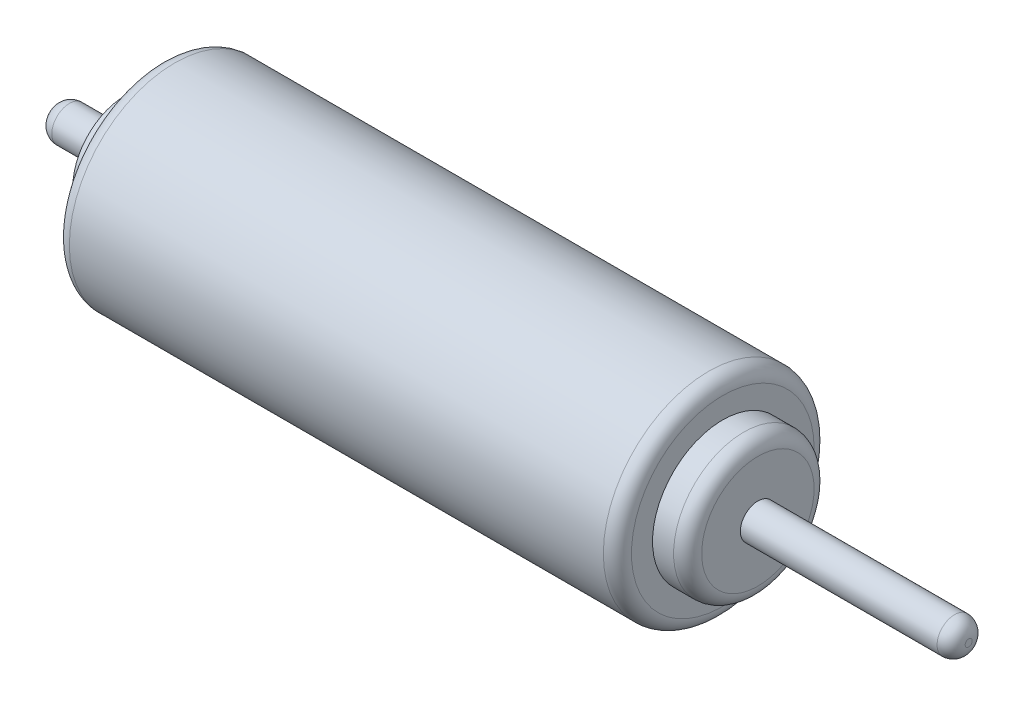
from build123d import *

# Parameters (mm, degrees)
SKETCH1_R           = 15
BOSS_EXTRUDE1_DEPTH = 80
SKETCH2_R           = 10
BOSS_EXTRUDE2_DEPTH = 5
SKETCH3_R           = 2.5
BOSS_EXTRUDE3_DEPTH = 30
FILLET1_R           = 2
FILLET2_R           = 2
FILLET3_R           = 2
SKETCH4_R           = 7.5
BOSS_EXTRUDE5_DEPTH = 5
SKETCH5_R           = 2.5
BOSS_EXTRUDE6_DEPTH = 10
FILLET4_R           = 2


with BuildPart() as part:
    # Sketch1 → Boss-Extrude1 (new body)
    with BuildSketch(Plane(origin=(0, 0, 0), x_dir=(0, 0, -1), z_dir=(1, 0, 0))):
        Circle(SKETCH1_R)
    extrude(amount=BOSS_EXTRUDE1_DEPTH)

    # Sketch2 → Boss-Extrude2 (add)
    with BuildSketch(Plane(origin=(80, 0, 0), x_dir=(0, 0, -1), z_dir=(1, 0, 0))):
        Circle(SKETCH2_R)
    extrude(amount=BOSS_EXTRUDE2_DEPTH)

    # Sketch3 → Boss-Extrude3 (add)
    with BuildSketch(Plane(origin=(85, 0, 0), x_dir=(0, 0, -1), z_dir=(1, 0, 0))):
        Circle(SKETCH3_R)
    extrude(amount=BOSS_EXTRUDE3_DEPTH)

    # Fillet1
    fillet1_edges = [part.edges().sort_by_distance(p)[0] for p in [
        (80, 0, 15),
    ]]
    fillet(fillet1_edges, radius=FILLET1_R)

    # Fillet2
    fillet2_edges = [part.edges().sort_by_distance(p)[0] for p in [
        (85, 0, 10),
    ]]
    fillet(fillet2_edges, radius=FILLET2_R)

    # Fillet3
    fillet3_edges = [part.edges().sort_by_distance(p)[0] for p in [
        (0, 0, 15),
    ]]
    fillet(fillet3_edges, radius=FILLET3_R)

    # Sketch4 → Boss-Extrude5 (add)
    with BuildSketch(Plane.ZY):
        Circle(SKETCH4_R)
    extrude(amount=BOSS_EXTRUDE5_DEPTH)

    # Sketch5 → Boss-Extrude6 (add)
    with BuildSketch(Plane.ZY.offset(5)):
        Circle(SKETCH5_R)
    extrude(amount=BOSS_EXTRUDE6_DEPTH)

    # Fillet4
    fillet4_edges = [part.edges().sort_by_distance(p)[0] for p in [
        (115, 0, 2.5),
        (-15, 0, -2.5),
    ]]
    fillet(fillet4_edges, radius=FILLET4_R)


solid = part.part
